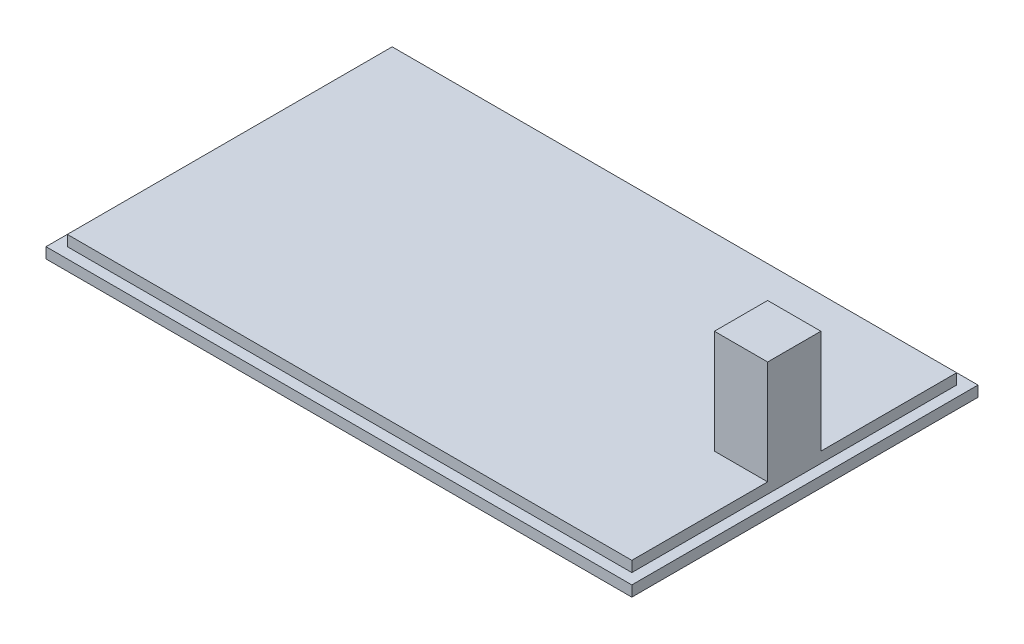
from build123d import *

# Parameters (mm, degrees)
SKETCH1_W           = 110
SKETCH1_H           = 65
BOSS_EXTRUDE1_DEPTH = 2
SKETCH2_W           = 106
SKETCH2_H           = 61
BOSS_EXTRUDE3_DEPTH = 2
SKETCH6_W           = 10
SKETCH6_H           = 10
BOSS_EXTRUDE4_DEPTH = 19.5


with BuildPart() as part:
    # Sketch1 → Boss-Extrude1 (new body)
    with BuildSketch(Plane(origin=(0, 0, 0), x_dir=(1, 0, 0), z_dir=(0, 1, 0))):
        with Locations((-2.954873439, 1.833455829)):
            Rectangle(SKETCH1_W, SKETCH1_H)
    extrude(amount=BOSS_EXTRUDE1_DEPTH)

    # Sketch2 → Boss-Extrude3 (add)
    with BuildSketch(Plane(origin=(0, 2, 0), x_dir=(1, 0, 0), z_dir=(0, 1, 0))):
        with Locations((-2.954873439, 1.833455829)):
            Rectangle(SKETCH2_W, SKETCH2_H)
    extrude(amount=BOSS_EXTRUDE3_DEPTH)

    # Sketch6 → Boss-Extrude4 (add)
    with BuildSketch(Plane(origin=(0, 4, 0), x_dir=(1, 0, 0), z_dir=(0, 1, 0))):
        with Locations((45.045126561, 1.833455829)):
            Rectangle(SKETCH6_W, SKETCH6_H)
    extrude(amount=BOSS_EXTRUDE4_DEPTH)


solid = part.part
